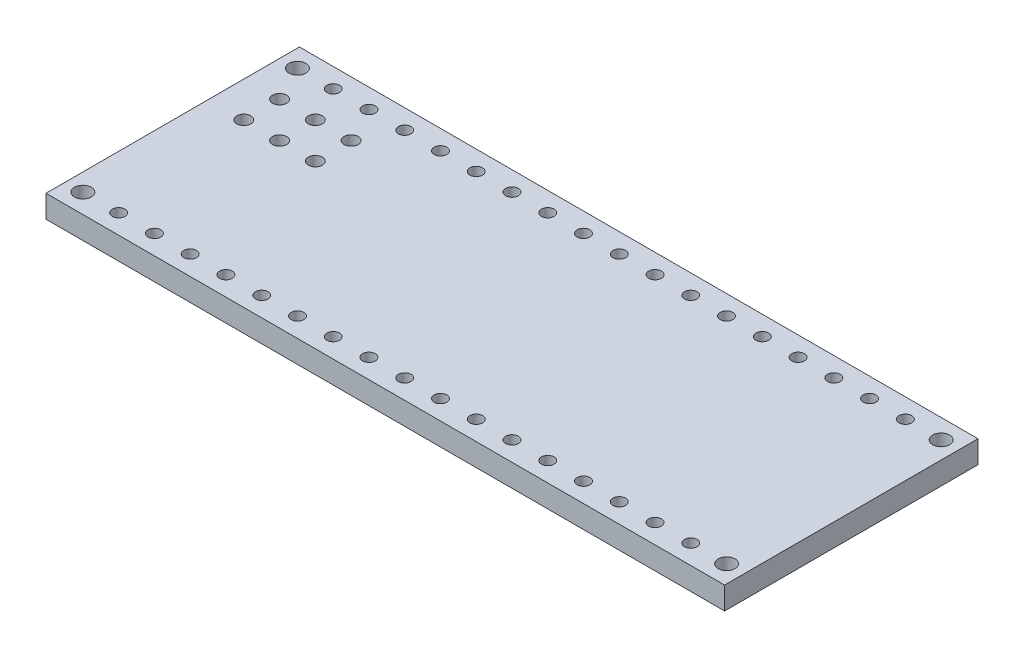
from build123d import *

# Parameters (mm, degrees)
SKETCH1_W           = 48.2
SKETCH1_H           = 18
SKETCH1_R           = 0.6
BOSS_EXTRUDE2_DEPTH = 1.6
SKETCH2_R           = 0.45
CUT_EXTRUDE2_DEPTH  = 1.6
LPATTERN1_COUNT     = 17
LPATTERN1_PITCH     = 2.54
SKETCH3_R           = 0.5
CUT_EXTRUDE4_DEPTH  = 1.6


with BuildPart() as part:
    # Sketch1 → Boss-Extrude2 (new body)
    with BuildSketch(Plane(origin=(0, 0, 0), x_dir=(1, 0, 0), z_dir=(0, 1, 0))):
        with Locations((20.32, 7.62)):
            Rectangle(SKETCH1_W, SKETCH1_H)
        with Locations((-2.54, 0)):
            Circle(SKETCH1_R, mode=Mode.SUBTRACT)
        with Locations((-2.54, 15.24)):
            Circle(SKETCH1_R, mode=Mode.SUBTRACT)
        with Locations((43.18, 15.24)):
            Circle(SKETCH1_R, mode=Mode.SUBTRACT)
        with Locations((43.18, 0)):
            Circle(SKETCH1_R, mode=Mode.SUBTRACT)
    extrude(amount=BOSS_EXTRUDE2_DEPTH)

    # Sketch2 → Cut-Extrude2 (cut)
    with BuildSketch(Plane(origin=(0, 0, 0), x_dir=(1, 0, 0), z_dir=(0, 1, 0))):
        Circle(SKETCH2_R)
        with Locations((0, 15.24)):
            Circle(SKETCH2_R)
    cut_extrude2 = extrude(amount=CUT_EXTRUDE2_DEPTH, mode=Mode.SUBTRACT)

    # LPattern1: Cut-Extrude2 ×17
    with Locations(*[(i * LPATTERN1_PITCH, 0, 0) for i in range(1, LPATTERN1_COUNT)]):
        add(cut_extrude2, mode=Mode.SUBTRACT)

    # Sketch3 → Cut-Extrude4 (cut)
    with BuildSketch(Plane(origin=(0, 0, 0), x_dir=(1, 0, 0), z_dir=(0, 1, 0))):
        with Locations((1.27, 12.7)):
            Circle(SKETCH3_R)
        with Locations((-1.27, 12.7)):
            Circle(SKETCH3_R)
        with Locations((-1.27, 10.16)):
            Circle(SKETCH3_R)
        with Locations((3.81, 12.7)):
            Circle(SKETCH3_R)
        with Locations((3.81, 10.16)):
            Circle(SKETCH3_R)
        with Locations((1.27, 10.16)):
            Circle(SKETCH3_R)
    extrude(amount=CUT_EXTRUDE4_DEPTH, mode=Mode.SUBTRACT)


solid = part.part
